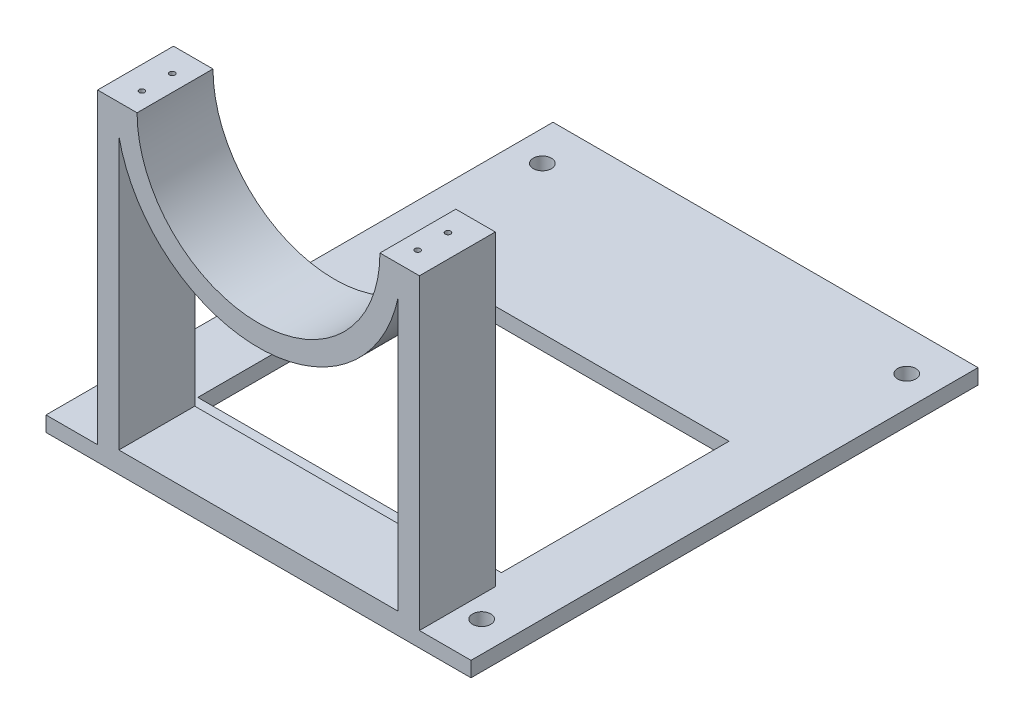
from build123d import *

# Parameters (mm, degrees)
BOSS_EXTRUDE1_DEPTH       = 15.875
SHELL1_T                  = -8.89
F_4_40_TAPPED_HOLE1_D     = 2.2606
F_4_40_TAPPED_HOLE1_DEPTH = 7.62
F_4_40_TAPPED_HOLE1_TIP   = 0.679153
SKETCH6_W                 = 180.34
SKETCH6_H                 = 6.35
BOSS_EXTRUDE2_DEPTH       = 177.8
SKETCH7_W                 = 127
SKETCH7_H                 = 95.25
CUT_EXTRUDE2_DEPTH        = 7.62
CUT_EXTRUDE3_REACH        = 256.155


with BuildPart() as part:
    # Sketch1 → Boss-Extrude1 (new, symmetric)
    with BuildSketch(Plane.XY):
        with BuildLine():
            ThreePointArc((0, -50.8), (-35.921024, -35.921024), (-50.8, 0))
            Line((-50.8, 0), (-67.31, 0))
            Line((-67.31, 0), (-67.31, -128.524))
            Line((-67.31, -128.524), (-88.9, -128.524))
            Line((-88.9, -128.524), (-88.9, -134.874))
            Line((-88.9, -134.874), (0, -134.874))
            Line((0, -134.874), (0, -50.8))
        make_face()
        with BuildLine():
            ThreePointArc((50.8, 0), (35.921024, -35.921024), (0, -50.8))
            Line((0, -50.8), (0, -134.874))
            Line((0, -134.874), (88.9, -134.874))
            Line((88.9, -134.874), (88.9, -128.524))
            Line((88.9, -128.524), (67.31, -128.524))
            Line((67.31, -128.524), (67.31, 0))
            Line((67.31, 0), (50.8, 0))
        make_face()
    extrude(amount=BOSS_EXTRUDE1_DEPTH, both=True)

    # Shell1
    shell1_openings = [part.faces().sort_by_distance(p)[0] for p in [
        (0, -81.597488, 15.875),
        (0, -81.597488, -15.875),
    ]]
    offset(amount=SHELL1_T, openings=shell1_openings)

    # #4-40 Tapped Hole1
    with Locations(Plane(origin=(0, 0, 0), x_dir=(1, 0, 0), z_dir=(0, 1, 0))):
        with Locations((-57.658, 5.715), (-57.658, -6.985), (57.658, -6.985), (57.658, 5.715)):
            Hole(F_4_40_TAPPED_HOLE1_D / 2, depth=F_4_40_TAPPED_HOLE1_DEPTH)
            with Locations((0, 0, -(F_4_40_TAPPED_HOLE1_DEPTH + F_4_40_TAPPED_HOLE1_TIP / 2))):  # 118° drill point
                Cone(0, F_4_40_TAPPED_HOLE1_D / 2, F_4_40_TAPPED_HOLE1_TIP, mode=Mode.SUBTRACT)

    # Sketch6 → Boss-Extrude2 (add)
    with BuildSketch(Plane(origin=(88.9, 0, 0), x_dir=(0, 0, -1), z_dir=(1, 0, 0))):
        with Locations((106.045, -131.699)):
            Rectangle(SKETCH6_W, SKETCH6_H)
    extrude(amount=-BOSS_EXTRUDE2_DEPTH)

    # Sketch7 → Cut-Extrude2 (cut)
    with BuildSketch(Plane.XZ.offset(134.874)):
        with Locations((0, -69.85)):
            Rectangle(SKETCH7_W, SKETCH7_H)
    extrude(amount=-CUT_EXTRUDE2_DEPTH, mode=Mode.SUBTRACT)

    # Sketch8 → Cut-Extrude3 (cut, up to next)
    with BuildSketch(Plane.XZ.offset(134.874), mode=Mode.PRIVATE) as cut_extrude3_sk1:
        with BuildLine():
            ThreePointArc((72.39, -1.27), (73.505923, -3.964077), (76.2, -5.08))
            Line((76.2, -5.08), (76.2, -1.27))
            Line((76.2, -1.27), (72.39, -1.27))
        make_face()
    cut_extrude3_tool1 = extrude(cut_extrude3_sk1.sketch, amount=-CUT_EXTRUDE3_REACH, mode=Mode.PRIVATE) & part.part
    # Sketch8 → Cut-Extrude3 (cut, up to next)
    with BuildSketch(Plane.XZ.offset(134.874), mode=Mode.PRIVATE) as cut_extrude3_sk2:
        with BuildLine():
            Line((76.2, -1.27), (76.2, -5.08))
            ThreePointArc((76.2, -5.08), (78.894077, -3.964077), (80.01, -1.27))
            ThreePointArc((80.01, -1.27), (76.2, 2.54), (72.39, -1.27))
            Line((72.39, -1.27), (76.2, -1.27))
        make_face()
    cut_extrude3_tool2 = extrude(cut_extrude3_sk2.sketch, amount=-CUT_EXTRUDE3_REACH, mode=Mode.PRIVATE) & part.part
    # Sketch8 → Cut-Extrude3 (cut, up to next)
    with BuildSketch(Plane.XZ.offset(134.874), mode=Mode.PRIVATE) as cut_extrude3_sk3:
        with BuildLine():
            ThreePointArc((72.39, -1.27), (73.505923, -3.964077), (76.2, -5.08))
            Line((76.2, -5.08), (76.2, -1.27))
            Line((76.2, -1.27), (72.39, -1.27))
        make_face()
    cut_extrude3_tool3 = extrude(cut_extrude3_sk3.sketch, amount=-CUT_EXTRUDE3_REACH, mode=Mode.PRIVATE) & part.part
    # Sketch8 → Cut-Extrude3 (cut, up to next)
    with BuildSketch(Plane.XZ.offset(134.874), mode=Mode.PRIVATE) as cut_extrude3_sk4:
        with BuildLine():
            Line((76.2, -1.27), (76.2, -5.08))
            ThreePointArc((76.2, -5.08), (78.894077, -3.964077), (80.01, -1.27))
            ThreePointArc((80.01, -1.27), (76.2, 2.54), (72.39, -1.27))
            Line((72.39, -1.27), (76.2, -1.27))
        make_face()
    cut_extrude3_tool4 = extrude(cut_extrude3_sk4.sketch, amount=-CUT_EXTRUDE3_REACH, mode=Mode.PRIVATE) & part.part
    # Sketch8 → Cut-Extrude3 (cut, up to next)
    with BuildSketch(Plane.XZ.offset(134.874), mode=Mode.PRIVATE) as cut_extrude3_sk5:
        with BuildLine():
            ThreePointArc((-72.39, -1.27), (-78.894077, 1.424077), (-76.2, -5.08))
            Line((-76.2, -5.08), (-76.2, -1.27))
            Line((-76.2, -1.27), (-72.39, -1.27))
        make_face()
    cut_extrude3_tool5 = extrude(cut_extrude3_sk5.sketch, amount=-CUT_EXTRUDE3_REACH, mode=Mode.PRIVATE) & part.part
    # Sketch8 → Cut-Extrude3 (cut, up to next)
    with BuildSketch(Plane.XZ.offset(134.874), mode=Mode.PRIVATE) as cut_extrude3_sk6:
        with BuildLine():
            Line((-76.2, -1.27), (-76.2, -5.08))
            ThreePointArc((-76.2, -5.08), (-73.505923, -3.964077), (-72.39, -1.27))
            Line((-72.39, -1.27), (-76.2, -1.27))
        make_face()
    cut_extrude3_tool6 = extrude(cut_extrude3_sk6.sketch, amount=-CUT_EXTRUDE3_REACH, mode=Mode.PRIVATE) & part.part
    # Sketch8 → Cut-Extrude3 (cut, up to next)
    with BuildSketch(Plane.XZ.offset(134.874), mode=Mode.PRIVATE) as cut_extrude3_sk7:
        with BuildLine():
            ThreePointArc((-72.39, -1.27), (-78.894077, 1.424077), (-76.2, -5.08))
            Line((-76.2, -5.08), (-76.2, -1.27))
            Line((-76.2, -1.27), (-72.39, -1.27))
        make_face()
    cut_extrude3_tool7 = extrude(cut_extrude3_sk7.sketch, amount=-CUT_EXTRUDE3_REACH, mode=Mode.PRIVATE) & part.part
    # Sketch8 → Cut-Extrude3 (cut, up to next)
    with BuildSketch(Plane.XZ.offset(134.874), mode=Mode.PRIVATE) as cut_extrude3_sk8:
        with BuildLine():
            Line((-76.2, -1.27), (-76.2, -5.08))
            ThreePointArc((-76.2, -5.08), (-73.505923, -3.964077), (-72.39, -1.27))
            Line((-72.39, -1.27), (-76.2, -1.27))
        make_face()
    cut_extrude3_tool8 = extrude(cut_extrude3_sk8.sketch, amount=-CUT_EXTRUDE3_REACH, mode=Mode.PRIVATE) & part.part
    # Sketch8 → Cut-Extrude3 (cut, up to next)
    with BuildSketch(Plane.XZ.offset(134.874), mode=Mode.PRIVATE) as cut_extrude3_sk9:
        with BuildLine():
            ThreePointArc((-76.2, -175.26), (-78.894077, -181.764077), (-72.39, -179.07))
            Line((-72.39, -179.07), (-76.2, -179.07))
            Line((-76.2, -179.07), (-76.2, -175.26))
        make_face()
    cut_extrude3_tool9 = extrude(cut_extrude3_sk9.sketch, amount=-CUT_EXTRUDE3_REACH, mode=Mode.PRIVATE) & part.part
    # Sketch8 → Cut-Extrude3 (cut, up to next)
    with BuildSketch(Plane.XZ.offset(134.874), mode=Mode.PRIVATE) as cut_extrude3_sk10:
        with BuildLine():
            Line((-76.2, -179.07), (-72.39, -179.07))
            ThreePointArc((-72.39, -179.07), (-73.505923, -176.375923), (-76.2, -175.26))
            Line((-76.2, -175.26), (-76.2, -179.07))
        make_face()
    cut_extrude3_tool10 = extrude(cut_extrude3_sk10.sketch, amount=-CUT_EXTRUDE3_REACH, mode=Mode.PRIVATE) & part.part
    # Sketch8 → Cut-Extrude3 (cut, up to next)
    with BuildSketch(Plane.XZ.offset(134.874), mode=Mode.PRIVATE) as cut_extrude3_sk11:
        with BuildLine():
            ThreePointArc((-76.2, -175.26), (-78.894077, -181.764077), (-72.39, -179.07))
            Line((-72.39, -179.07), (-76.2, -179.07))
            Line((-76.2, -179.07), (-76.2, -175.26))
        make_face()
    cut_extrude3_tool11 = extrude(cut_extrude3_sk11.sketch, amount=-CUT_EXTRUDE3_REACH, mode=Mode.PRIVATE) & part.part
    # Sketch8 → Cut-Extrude3 (cut, up to next)
    with BuildSketch(Plane.XZ.offset(134.874), mode=Mode.PRIVATE) as cut_extrude3_sk12:
        with BuildLine():
            Line((-76.2, -179.07), (-72.39, -179.07))
            ThreePointArc((-72.39, -179.07), (-73.505923, -176.375923), (-76.2, -175.26))
            Line((-76.2, -175.26), (-76.2, -179.07))
        make_face()
    cut_extrude3_tool12 = extrude(cut_extrude3_sk12.sketch, amount=-CUT_EXTRUDE3_REACH, mode=Mode.PRIVATE) & part.part
    # Sketch8 → Cut-Extrude3 (cut, up to next)
    with BuildSketch(Plane.XZ.offset(134.874), mode=Mode.PRIVATE) as cut_extrude3_sk13:
        with BuildLine():
            ThreePointArc((76.2, -175.26), (73.505923, -176.375923), (72.39, -179.07))
            Line((72.39, -179.07), (76.2, -179.07))
            Line((76.2, -179.07), (76.2, -175.26))
        make_face()
    cut_extrude3_tool13 = extrude(cut_extrude3_sk13.sketch, amount=-CUT_EXTRUDE3_REACH, mode=Mode.PRIVATE) & part.part
    # Sketch8 → Cut-Extrude3 (cut, up to next)
    with BuildSketch(Plane.XZ.offset(134.874), mode=Mode.PRIVATE) as cut_extrude3_sk14:
        with BuildLine():
            Line((76.2, -179.07), (72.39, -179.07))
            ThreePointArc((72.39, -179.07), (76.2, -182.88), (80.01, -179.07))
            ThreePointArc((80.01, -179.07), (78.894077, -176.375923), (76.2, -175.26))
            Line((76.2, -175.26), (76.2, -179.07))
        make_face()
    cut_extrude3_tool14 = extrude(cut_extrude3_sk14.sketch, amount=-CUT_EXTRUDE3_REACH, mode=Mode.PRIVATE) & part.part
    # Sketch8 → Cut-Extrude3 (cut, up to next)
    with BuildSketch(Plane.XZ.offset(134.874), mode=Mode.PRIVATE) as cut_extrude3_sk15:
        with BuildLine():
            ThreePointArc((76.2, -175.26), (73.505923, -176.375923), (72.39, -179.07))
            Line((72.39, -179.07), (76.2, -179.07))
            Line((76.2, -179.07), (76.2, -175.26))
        make_face()
    cut_extrude3_tool15 = extrude(cut_extrude3_sk15.sketch, amount=-CUT_EXTRUDE3_REACH, mode=Mode.PRIVATE) & part.part
    # Sketch8 → Cut-Extrude3 (cut, up to next)
    with BuildSketch(Plane.XZ.offset(134.874), mode=Mode.PRIVATE) as cut_extrude3_sk16:
        with BuildLine():
            Line((76.2, -179.07), (72.39, -179.07))
            ThreePointArc((72.39, -179.07), (76.2, -182.88), (80.01, -179.07))
            ThreePointArc((80.01, -179.07), (78.894077, -176.375923), (76.2, -175.26))
            Line((76.2, -175.26), (76.2, -179.07))
        make_face()
    cut_extrude3_tool16 = extrude(cut_extrude3_sk16.sketch, amount=-CUT_EXTRUDE3_REACH, mode=Mode.PRIVATE) & part.part
    add(cut_extrude3_tool1.solids().sort_by_distance((74.582986, -134.874, -2.887014))[0], mode=Mode.SUBTRACT)
    add(cut_extrude3_tool2.solids().sort_by_distance((76.739005, -134.874, -0.730995))[0], mode=Mode.SUBTRACT)
    add(cut_extrude3_tool3.solids().sort_by_distance((74.582986, -134.874, -2.887014))[0], mode=Mode.SUBTRACT)
    add(cut_extrude3_tool4.solids().sort_by_distance((76.739005, -134.874, -0.730995))[0], mode=Mode.SUBTRACT)
    add(cut_extrude3_tool5.solids().sort_by_distance((-76.739005, -134.874, -0.730995))[0], mode=Mode.SUBTRACT)
    add(cut_extrude3_tool6.solids().sort_by_distance((-74.582986, -134.874, -2.887014))[0], mode=Mode.SUBTRACT)
    add(cut_extrude3_tool7.solids().sort_by_distance((-76.739005, -134.874, -0.730995))[0], mode=Mode.SUBTRACT)
    add(cut_extrude3_tool8.solids().sort_by_distance((-74.582986, -134.874, -2.887014))[0], mode=Mode.SUBTRACT)
    add(cut_extrude3_tool9.solids().sort_by_distance((-76.739005, -134.874, -179.609005))[0], mode=Mode.SUBTRACT)
    add(cut_extrude3_tool10.solids().sort_by_distance((-74.582986, -134.874, -177.452986))[0], mode=Mode.SUBTRACT)
    add(cut_extrude3_tool11.solids().sort_by_distance((-76.739005, -134.874, -179.609005))[0], mode=Mode.SUBTRACT)
    add(cut_extrude3_tool12.solids().sort_by_distance((-74.582986, -134.874, -177.452986))[0], mode=Mode.SUBTRACT)
    add(cut_extrude3_tool13.solids().sort_by_distance((74.582986, -134.874, -177.452986))[0], mode=Mode.SUBTRACT)
    add(cut_extrude3_tool14.solids().sort_by_distance((76.739005, -134.874, -179.609005))[0], mode=Mode.SUBTRACT)
    add(cut_extrude3_tool15.solids().sort_by_distance((74.582986, -134.874, -177.452986))[0], mode=Mode.SUBTRACT)
    add(cut_extrude3_tool16.solids().sort_by_distance((76.739005, -134.874, -179.609005))[0], mode=Mode.SUBTRACT)


solid = part.part
